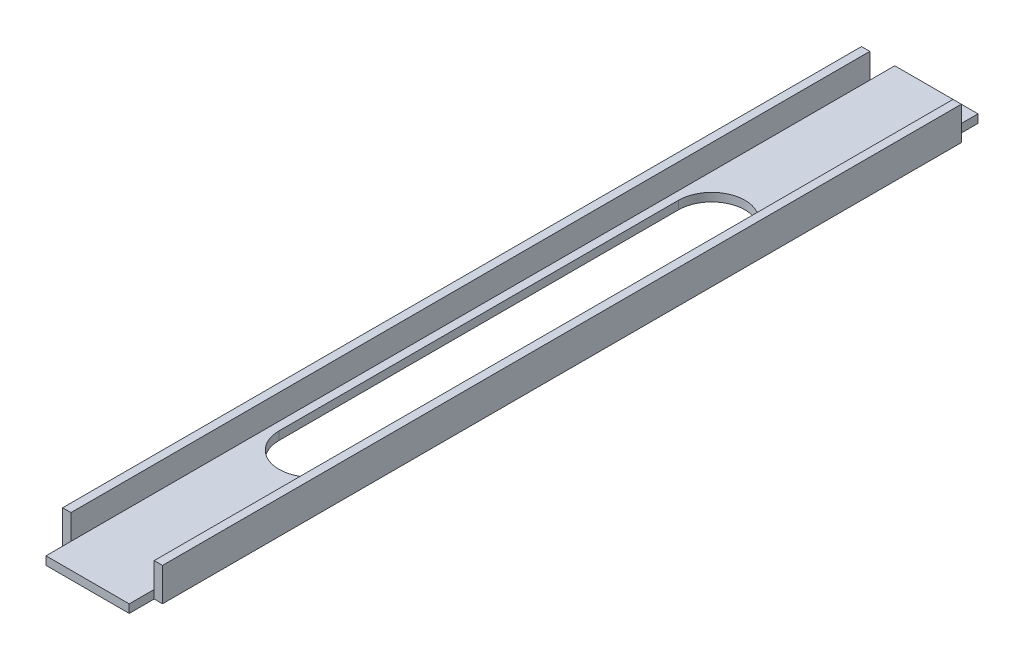
from build123d import *

# Parameters (mm, degrees)
BOSS_EXTRUDE1_DEPTH = 323.85
SKETCH2_W           = 9.525
SKETCH2_H           = 12.7
CUT_EXTRUDE1_DEPTH  = 3.175
CUT_EXTRUDE2_REACH  = 14.7


with BuildPart() as part:
    # Sketch1 → Boss-Extrude1 (new body)
    with BuildSketch(Plane.XY):
        Polygon((3.175, 3.175), (3.175, 12.7), (0, 12.7), (0, 0), (38.1, 0), (38.1, 12.7), (34.925, 12.7), (34.925, 3.175), align=None)
    extrude(amount=BOSS_EXTRUDE1_DEPTH)

    # Sketch2 → Cut-Extrude1 (cut)
    with BuildSketch(Plane.ZY):
        with Locations((319.0875, 6.35)):
            Rectangle(SKETCH2_W, SKETCH2_H)
        with Locations((4.7625, 6.35)):
            Rectangle(SKETCH2_W, SKETCH2_H)
    cut_extrude1 = extrude(amount=-CUT_EXTRUDE1_DEPTH, mode=Mode.SUBTRACT)

    # Mirror1: Cut-Extrude1 across plane
    add(cut_extrude1.mirror(Plane.ZY.offset(-19.05)), mode=Mode.SUBTRACT)

    # Sketch3 → Cut-Extrude2 (cut, up to next)
    with BuildSketch(Plane.XZ, mode=Mode.PRIVATE) as cut_extrude2_sk1:
        with BuildLine():
            Line((31.75, 238.125), (31.75, 85.725))
            ThreePointArc((31.75, 85.725), (19.05, 73.025), (6.35, 85.725))
            Line((6.35, 85.725), (6.35, 238.125))
            ThreePointArc((6.35, 238.125), (19.05, 250.825), (31.75, 238.125))
        make_face()
    cut_extrude2_tool1 = extrude(cut_extrude2_sk1.sketch, amount=-CUT_EXTRUDE2_REACH, mode=Mode.PRIVATE) & part.part
    add(cut_extrude2_tool1.solids().sort_by_distance((19.05, 0, 161.925))[0], mode=Mode.SUBTRACT)


solid = part.part
